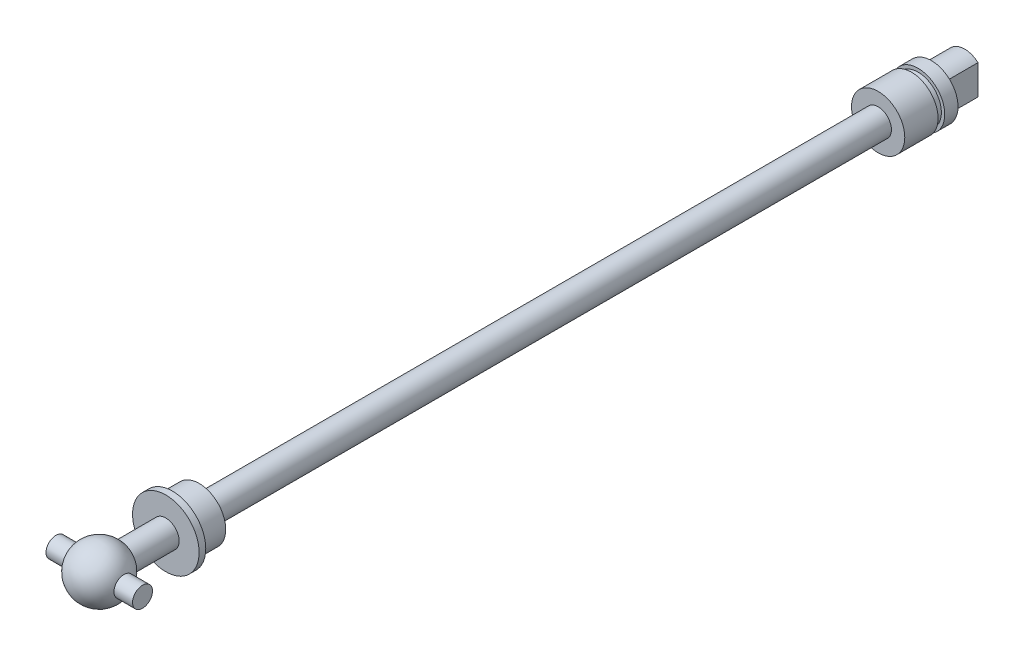
from build123d import *

# Parameters (mm, degrees)
CUT_EXTRUDE1_DEPTH  = 5
SKETCH3_R           = 1.5
BOSS_EXTRUDE1_DEPTH = 6.5


with BuildPart() as part:
    # Sketch1 → Revolve1 (revolve)
    with BuildSketch(Plane(origin=(0, 0, 0), x_dir=(0, 0, -1), z_dir=(1, 0, 0))):
        with BuildLine():
            Line((7.464101615, 2), (14, 2))
            Line((14, 2), (14, 5))
            Line((14, 5), (15, 5))
            Line((15, 5), (15, 4))
            Line((15, 4), (19, 4))
            Line((19, 4), (19, 2))
            Line((19, 2), (121, 2))
            Line((121, 2), (121, 4))
            Line((121, 4), (126, 4))
            Line((126, 4), (126, 3.5))
            Line((126, 3.5), (127, 3.5))
            Line((127, 3.5), (127, 4))
            Line((127, 4), (129, 4))
            Line((129, 4), (129, 3))
            Line((129, 3), (134, 3))
            Line((134, 3), (134, 0))
            Line((134, 0), (0, 0))
            ThreePointArc((0, 0), (2.96472382, 3.863703305), (7.464101615, 2))
        make_face()
    revolve(axis=Axis((0, 0, 0), (0, 0, -1)))

    # Sketch2 → Cut-Extrude1 (cut)
    with BuildSketch(Plane(origin=(0, 0, -134), x_dir=(-1, 0, 0), z_dir=(0, 0, -1))):
        with BuildLine():
            ThreePointArc((-2, 2.236067977), (-3, 0), (-2, -2.236067977))
            Line((-2, -2.236067977), (-2, 2.236067977))
        make_face()
        with BuildLine():
            Line((2, 2.236067977), (2, -2.236067977))
            ThreePointArc((2, -2.236067977), (2.738612788, -1.224744871), (3, 0))
            ThreePointArc((3, 0), (2.738612788, 1.224744871), (2, 2.236067977))
        make_face()
    extrude(amount=-CUT_EXTRUDE1_DEPTH, mode=Mode.SUBTRACT)

    # Sketch3 → Boss-Extrude1 (add, symmetric)
    with BuildSketch(Plane(origin=(0, 0, 0), x_dir=(0, 0, -1), z_dir=(1, 0, 0))):
        with Locations((4, 0)):
            Circle(SKETCH3_R)
    extrude(amount=BOSS_EXTRUDE1_DEPTH, both=True)


solid = part.part
